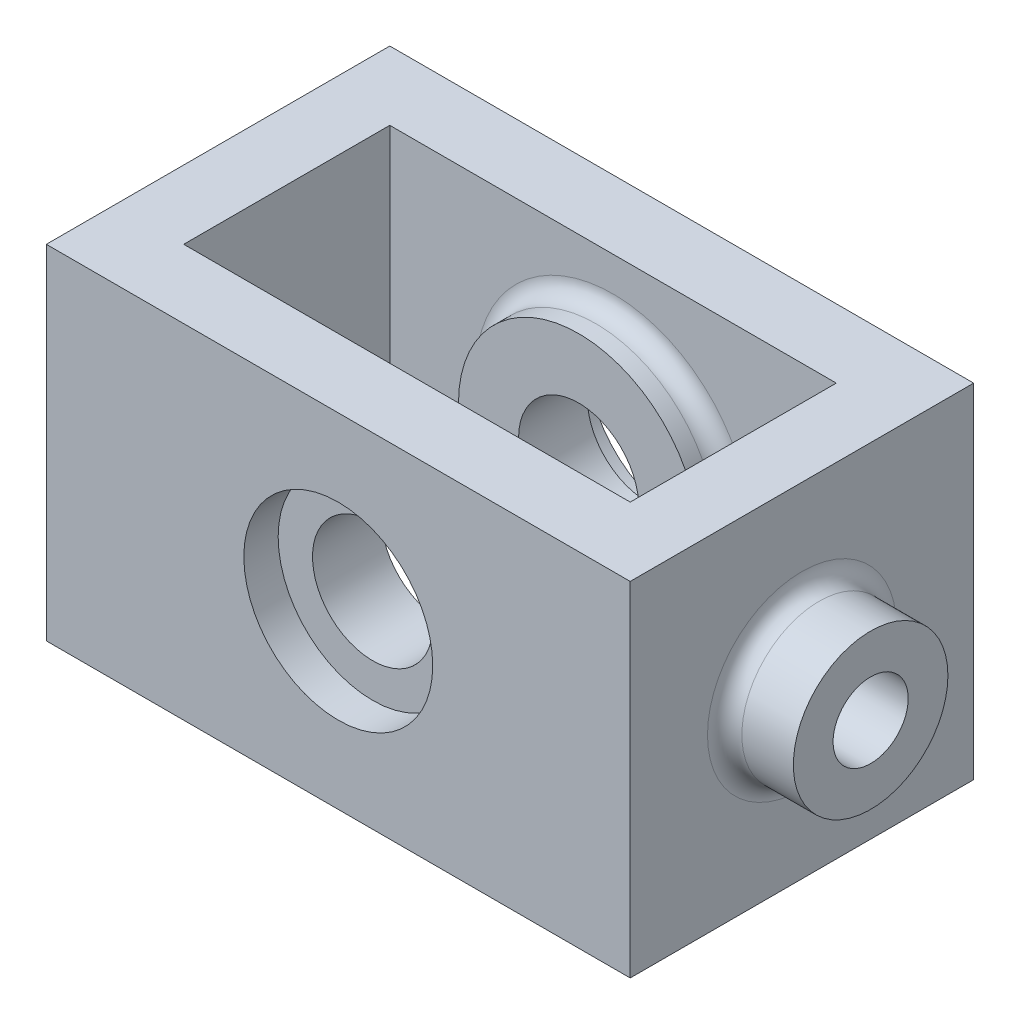
from build123d import *

# Parameters (mm, degrees)
SKETCH1_W           = 86.36
SKETCH1_H           = 50.8
SKETCH1_R           = 8.89
BOSS_EXTRUDE2_DEPTH = 25.4
CUT_EXTRUDE2_START  = 25.4
SKETCH1_3_R         = 13.97
SKETCH1_3_R_2       = 8.89
CUT_EXTRUDE2_DEPTH  = 5.08
CUT_EXTRUDE4_START  = -25.4
SKETCH1_4_R         = 13.97
SKETCH1_4_R_2       = 8.89
CUT_EXTRUDE4_DEPTH  = 5.08
SKETCH3_R           = 11.43
SKETCH3_R_2         = 5.55625
BOSS_EXTRUDE3_DEPTH = 10.16
SKETCH3_2_R         = 5.55625
CUT_EXTRUDE5_DEPTH  = 97.52
SKETCH4_W           = 66.04
SKETCH4_H           = 30.48
CUT_EXTRUDE6_DEPTH  = 51.8
BOSS_EXTRUDE4_START = 15.24
SKETCH5_R           = 17.78
SKETCH5_R_2         = 8.89
BOSS_EXTRUDE4_DEPTH = 5.08
BOSS_EXTRUDE5_START = -15.24
SKETCH5_2_R         = 17.78
SKETCH5_2_R_2       = 8.89
BOSS_EXTRUDE5_DEPTH = 5.08
FILLET1_R           = 2.54
FILLET2_R           = 2.54


with BuildPart() as part:
    # Sketch1 → Boss-Extrude2 (new body, symmetric)
    with BuildSketch(Plane.XY):
        Rectangle(SKETCH1_W, SKETCH1_H)
        Circle(SKETCH1_R, mode=Mode.SUBTRACT)
    extrude(amount=BOSS_EXTRUDE2_DEPTH, both=True)

    # Sketch1_3 → Cut-Extrude2 (cut)
    with BuildSketch(Plane.XY.offset(CUT_EXTRUDE2_START)):
        Circle(SKETCH1_3_R)
        Circle(SKETCH1_3_R_2, mode=Mode.SUBTRACT)
    extrude(amount=-CUT_EXTRUDE2_DEPTH, mode=Mode.SUBTRACT)

    # Sketch1_4 → Cut-Extrude4 (cut)
    with BuildSketch(Plane.XY.offset(CUT_EXTRUDE4_START)):
        Circle(SKETCH1_4_R)
        Circle(SKETCH1_4_R_2, mode=Mode.SUBTRACT)
    extrude(amount=CUT_EXTRUDE4_DEPTH, mode=Mode.SUBTRACT)

    # Sketch3 → Boss-Extrude3 (add)
    with BuildSketch(Plane(origin=(43.18, 0, 0), x_dir=(0, 0, -1), z_dir=(1, 0, 0))):
        Circle(SKETCH3_R)
        Circle(SKETCH3_R_2, mode=Mode.SUBTRACT)
    boss_extrude3 = extrude(amount=BOSS_EXTRUDE3_DEPTH)

    # Mirror1: Boss-Extrude3 across plane
    add(boss_extrude3.mirror(Plane(origin=(0, 0, 0), x_dir=(0, 0, 1), z_dir=(1, 0, 0))))

    # Sketch3_2 → Cut-Extrude5 (cut, through all)
    with BuildSketch(Plane(origin=(43.18, 0, 0), x_dir=(0, 0, -1), z_dir=(1, 0, 0))):
        Circle(SKETCH3_2_R)
    extrude(amount=-CUT_EXTRUDE5_DEPTH, mode=Mode.SUBTRACT)

    # Sketch4 → Cut-Extrude6 (cut, through all)
    with BuildSketch(Plane(origin=(0, 25.4, 0), x_dir=(1, 0, 0), z_dir=(0, 1, 0))):
        Rectangle(SKETCH4_W, SKETCH4_H)
    extrude(amount=-CUT_EXTRUDE6_DEPTH, mode=Mode.SUBTRACT)

    # Sketch5 → Boss-Extrude4 (add)
    with BuildSketch(Plane.XY.offset(BOSS_EXTRUDE4_START)):
        Circle(SKETCH5_R)
        Circle(SKETCH5_R_2, mode=Mode.SUBTRACT)
    extrude(amount=-BOSS_EXTRUDE4_DEPTH)

    # Sketch5_2 → Boss-Extrude5 (add)
    with BuildSketch(Plane.XY.offset(BOSS_EXTRUDE5_START)):
        Circle(SKETCH5_2_R)
        Circle(SKETCH5_2_R_2, mode=Mode.SUBTRACT)
    extrude(amount=BOSS_EXTRUDE5_DEPTH)

    # Fillet1
    fillet1_edges = [part.edges().sort_by_distance(p)[0] for p in [
        (-17.78, 0, 15.24),
        (-17.78, 0, -15.24),
    ]]
    fillet(fillet1_edges, radius=FILLET1_R)

    # Fillet2
    fillet2_edges = [part.edges().sort_by_distance(p)[0] for p in [
        (43.18, 0, 11.43),
        (-43.18, 0, 11.43),
    ]]
    fillet(fillet2_edges, radius=FILLET2_R)


solid = part.part
